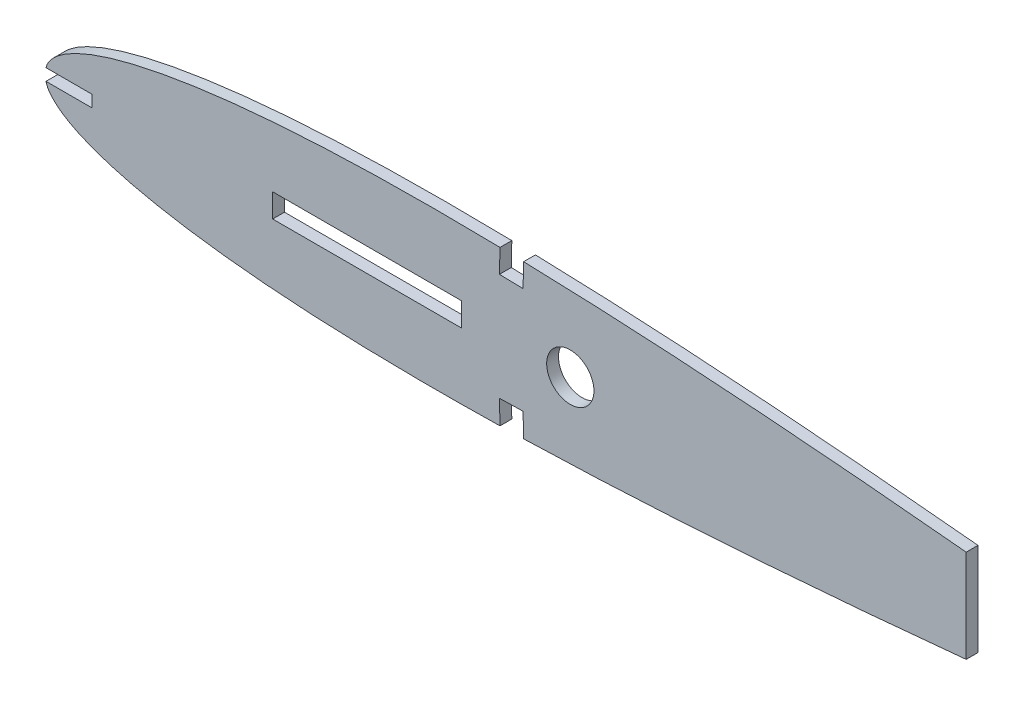
from build123d import *

# Parameters (mm, degrees)
BOSS_EXTRUDE1_DEPTH = 3.175
SKETCH3_R           = 6.35
SKETCH3_W           = 101.6
SKETCH3_H           = 101.6
SKETCH3_W_2         = 12.7
SKETCH3_H_2         = 3.175
CUT_EXTRUDE1_DEPTH  = 5.08
SKETCH4_W           = 50.8
SKETCH4_H           = 6.35
CUT_EXTRUDE2_DEPTH  = 5.08


with BuildPart() as part:
    # Sketch2 → Boss-Extrude1 (new body)
    with BuildSketch(Plane.XY):
        with BuildLine():
            add(Edge.make_bspline(
                [(349.25, 0), (349.081845346, 0.195028946), (348.546486748, 0.815947966), (346.670763268, 0.635287815), (344.11086643, 1.231330826), (340.348873806, 1.640765335), (335.631665172, 2.319189902), (329.896669995, 3.064968776), (323.213152208, 3.937751592), (315.610665982, 4.899637326), (307.139892382, 5.94572983), (297.851820227, 7.058039906), (287.804163994, 8.223966301), (277.05860736, 9.42727111), (265.681494766, 10.653371923), (253.743033604, 11.887008331), (241.316804275, 13.11226643), (228.479451099, 14.31194461), (215.310032455, 15.470294327), (201.889886046, 16.567949836), (188.301472832, 17.587013879), (174.628693344, 18.508566703), (160.95579103, 19.313339436), (147.366939387, 19.981000511), (133.946062727, 20.493746123), (120.775518049, 20.834848585), (107.936696619, 20.987647162), (95.508487727, 20.940015693), (83.567514363, 20.682753776), (72.187279219, 20.209340103), (61.437827927, 19.518536296), (51.385233466, 18.612420938), (42.090988888, 17.498070831), (33.611817078, 16.184967443), (25.998868366, 14.686825017), (19.297496021, 13.02058345), (13.543519177, 11.202490675), (8.772941595, 9.249479701), (4.98137124, 7.174763565), (2.229693173, 4.974247418), (0.364862544, 2.594695774), (0.115985535, 0.824823436), (0, 0)],
                knots=[0, 0, 0, 0, 0.002091853, 0.006659889, 0.014240034, 0.024784942, 0.038226646, 0.054481348, 0.073444809, 0.094998776, 0.11900639, 0.145318898, 0.173770288, 0.204183654, 0.236370679, 0.270129473, 0.305250351, 0.341516861, 0.378701149, 0.416575318, 0.454902219, 0.493447217, 0.531971459, 0.57023708, 0.608012632, 0.645066312, 0.681178002, 0.716129843, 0.74971807, 0.781748295, 0.812036536, 0.840415327, 0.866732056, 0.890849065, 0.912651845, 0.932046273, 0.94897292, 0.963413199, 0.975421325, 0.985175212, 0.993091122, 1, 1, 1, 1], degree=3))
            add(Edge.make_bspline(
                [(349.25, 0), (349.081845346, -0.195028946), (348.546486748, -0.815947966), (346.670763268, -0.635287815), (344.11086643, -1.231330826), (340.348873806, -1.640765335), (335.631665172, -2.319189902), (329.896669995, -3.064968776), (323.213152208, -3.937751592), (315.610665982, -4.899637326), (307.139892382, -5.94572983), (297.851820227, -7.058039906), (287.804163994, -8.223966301), (277.05860736, -9.42727111), (265.681494766, -10.653371923), (253.743033604, -11.887008331), (241.316804275, -13.11226643), (228.479451099, -14.31194461), (215.310032455, -15.470294327), (201.889886046, -16.567949836), (188.301472832, -17.587013879), (174.628693344, -18.508566703), (160.95579103, -19.313339436), (147.366939387, -19.981000511), (133.946062727, -20.493746123), (120.775518049, -20.834848585), (107.936696619, -20.987647162), (95.508487727, -20.940015693), (83.567514363, -20.682753776), (72.187279219, -20.209340103), (61.437827927, -19.518536296), (51.385233466, -18.612420938), (42.090988888, -17.498070831), (33.611817078, -16.184967443), (25.998868366, -14.686825017), (19.297496021, -13.02058345), (13.543519177, -11.202490675), (8.772941595, -9.249479701), (4.98137124, -7.174763565), (2.229693173, -4.974247418), (0.364862544, -2.594695774), (0.115985535, -0.824823436), (0, 0)],
                knots=[0, 0, 0, 0, 0.002091853, 0.006659889, 0.014240034, 0.024784942, 0.038226646, 0.054481348, 0.073444809, 0.094998776, 0.11900639, 0.145318898, 0.173770288, 0.204183654, 0.236370679, 0.270129473, 0.305250351, 0.341516861, 0.378701149, 0.416575318, 0.454902219, 0.493447217, 0.531971459, 0.57023708, 0.608012632, 0.645066312, 0.681178002, 0.716129843, 0.74971807, 0.781748295, 0.812036536, 0.840415327, 0.866732056, 0.890849065, 0.912651845, 0.932046273, 0.94897292, 0.963413199, 0.975421325, 0.985175212, 0.993091122, 1, 1, 1, 1], degree=3))
        make_face()
    extrude(amount=BOSS_EXTRUDE1_DEPTH)

    # Sketch3 → Cut-Extrude1 (cut)
    with BuildSketch(Plane.XY.offset(3.175)):
        with Locations((141.224, 0)):
            Circle(SKETCH3_R)
        with Locations((298.45, 0)):
            Rectangle(SKETCH3_W, SKETCH3_H)
        with Locations((6.35, 0)):
            Rectangle(SKETCH3_W_2, SKETCH3_H_2)
        Polygon((128.675427045, -20.622361952), (128.524, -14.274167732), (122.17580578, -14.425594777), (122.327232825, -20.773788997), (122.630086914, -33.470177436), (128.978281134, -33.318750391), align=None)
        Polygon((128.524, 14.274167732), (122.17580578, 14.425594777), (122.327232825, 20.773788997), (122.552222293, 30.205900992), (128.900416513, 30.054473947), (128.675427045, 20.622361952), align=None)
    extrude(amount=-CUT_EXTRUDE1_DEPTH, mode=Mode.SUBTRACT)

    # Sketch4 → Cut-Extrude2 (cut)
    with BuildSketch(Plane.XY.offset(3.175)):
        with Locations((86.614, 0)):
            Rectangle(SKETCH4_W, SKETCH4_H)
    extrude(amount=-CUT_EXTRUDE2_DEPTH, mode=Mode.SUBTRACT)


solid = part.part
